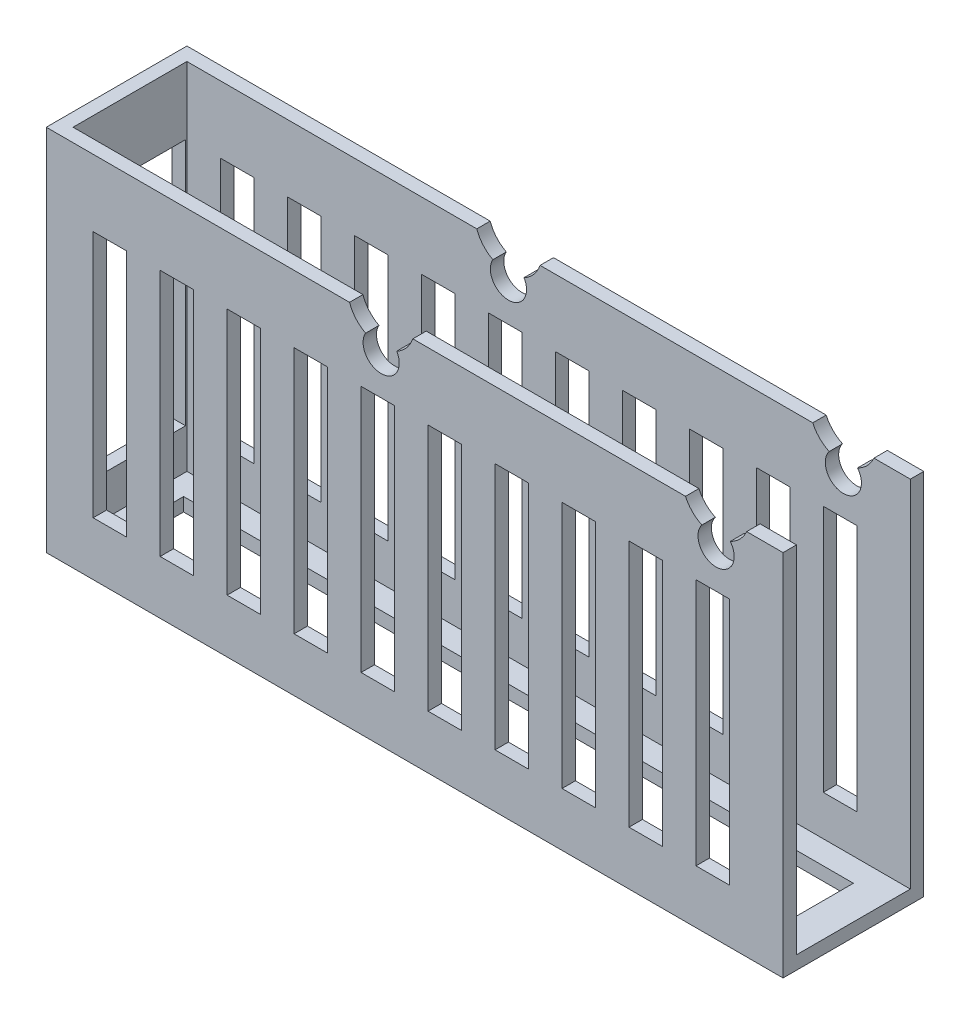
from build123d import *

# Parameters (mm, degrees)
SKETCH_1_W           = 110
SKETCH_1_H           = 21
EXTRUDE_1_DEPTH      = 55
SHELL_1_T            = -2
SKETCH_2_W           = 17
SKETCH_2_H           = 53
CUT_EXTRUDE_1_DEPTH  = 50
SKETCH_8_W           = 5
SKETCH_8_H           = 37
CUT_EXTRUDE_8_DEPTH  = 22
SKETCH_9_W           = 16.817883905
SKETCH_9_H           = 37
CUT_EXTRUDE_9_DEPTH  = 111
SKETCH_10_W          = 100
SKETCH_10_H          = 10
CUT_EXTRUDE_10_DEPTH = 56
CUT_EXTRUDE_11_DEPTH = 22


with BuildPart() as part:
    # 草图1 → 凸台-拉伸1 (new body)
    with BuildSketch(Plane(origin=(0, 0, 0), x_dir=(1, 0, 0), z_dir=(0, 1, 0))):
        Rectangle(SKETCH_1_W, SKETCH_1_H)
    extrude(amount=EXTRUDE_1_DEPTH)

    # 抽壳1
    shell_1_openings = [part.faces().sort_by_distance(p)[0] for p in [
        (0, 55, 0),
    ]]
    offset(amount=SHELL_1_T, openings=shell_1_openings, kind=Kind.INTERSECTION)

    # 草图2 → 切除-拉伸1 (cut)
    with BuildSketch(Plane(origin=(55, 0, 0), x_dir=(0, 0, -1), z_dir=(1, 0, 0))):
        with Locations((0, 28.5)):
            Rectangle(SKETCH_2_W, SKETCH_2_H)
    extrude(amount=-CUT_EXTRUDE_1_DEPTH, mode=Mode.SUBTRACT)

    # 草图8 → 切除-拉伸8 (cut, through all)
    with BuildSketch(Plane(origin=(0, 0, -10.5), x_dir=(-1, 0, 0), z_dir=(0, 0, -1))):
        with Locations((-34.5, 26.5)):
            Rectangle(SKETCH_8_W, SKETCH_8_H)
        with Locations((-44.5, 26.5)):
            Rectangle(SKETCH_8_W, SKETCH_8_H)
        with Locations((-24.5, 26.5)):
            Rectangle(SKETCH_8_W, SKETCH_8_H)
        with Locations((-14.5, 26.5)):
            Rectangle(SKETCH_8_W, SKETCH_8_H)
        with Locations((-4.5, 26.5)):
            Rectangle(SKETCH_8_W, SKETCH_8_H)
        with Locations((5.5, 26.5)):
            Rectangle(SKETCH_8_W, SKETCH_8_H)
        with Locations((15.5, 26.5)):
            Rectangle(SKETCH_8_W, SKETCH_8_H)
        with Locations((25.5, 26.5)):
            Rectangle(SKETCH_8_W, SKETCH_8_H)
        with Locations((35.5, 26.5)):
            Rectangle(SKETCH_8_W, SKETCH_8_H)
        with Locations((45.5, 26.5)):
            Rectangle(SKETCH_8_W, SKETCH_8_H)
    extrude(amount=-CUT_EXTRUDE_8_DEPTH, mode=Mode.SUBTRACT)

    # 草图9 → 切除-拉伸9 (cut, through all)
    with BuildSketch(Plane.ZY.offset(55)):
        with Locations((0.111623124, 26.5)):
            Rectangle(SKETCH_9_W, SKETCH_9_H)
    extrude(amount=-CUT_EXTRUDE_9_DEPTH, mode=Mode.SUBTRACT)

    # 草图10 → 切除-拉伸10 (cut, through all)
    with BuildSketch(Plane.XZ):
        Rectangle(SKETCH_10_W, SKETCH_10_H)
    extrude(amount=-CUT_EXTRUDE_10_DEPTH, mode=Mode.SUBTRACT)

    # 草图5 → 切除-拉伸11 (cut, through all)
    with BuildSketch(Plane(origin=(0, 0, -10.5), x_dir=(-1, 0, 0), z_dir=(0, 0, -1))):
        with BuildLine():
            ThreePointArc((-47.120181843, 52.510910871), (-45, 48.139136677), (-42.879818157, 52.510910871))
            ThreePointArc((-42.879818157, 52.510910871), (-45, 62.039136677), (-47.120181843, 52.510910871))
        make_face()
        with BuildLine():
            ThreePointArc((2.675165182, 52.212141801), (5, 48.139136677), (7.324834818, 52.212141801))
            ThreePointArc((7.324834818, 52.212141801), (5, 61.638781957), (2.675165182, 52.212141801))
        make_face()
    extrude(amount=-CUT_EXTRUDE_11_DEPTH, mode=Mode.SUBTRACT)


solid = part.part
